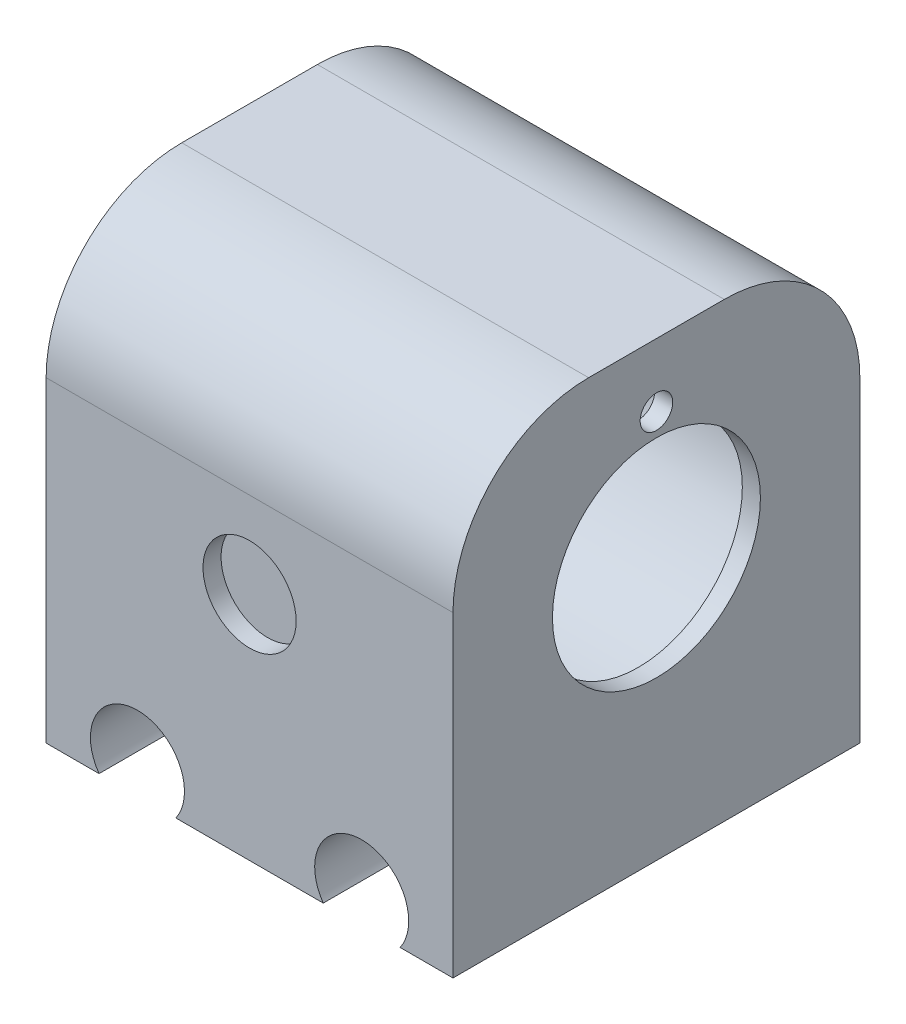
from build123d import *

# Parameters (mm, degrees)
SKETCH1_W           = 45
SKETCH1_H           = 50
BOSS_EXTRUDE1_DEPTH = 45
SKETCH2_R           = 5.2
CUT_EXTRUDE1_DEPTH  = 45
SKETCH9_R           = 5.15
CUT_EXTRUDE6_DEPTH  = 2
SKETCH10_R          = 5.15
CUT_EXTRUDE7_DEPTH  = 2
SKETCH12_R          = 18.375
CUT_EXTRUDE8_DEPTH  = 45
SKETCH13_W          = 45
SKETCH13_H          = 6.66747138
CUT_EXTRUDE9_DEPTH  = 46
SKETCH14_W          = 45
SKETCH14_H          = 6.66747138
BOSS_EXTRUDE2_DEPTH = 45
SKETCH15_R          = 18.375
CUT_EXTRUDE10_DEPTH = 45
FILLET1_R           = 15
SKETCH16_R          = 18.375
BOSS_EXTRUDE3_DEPTH = 2
SKETCH17_R          = 11.5
CUT_EXTRUDE11_DEPTH = 2
SKETCH18_R          = 1.8
CUT_EXTRUDE12_DEPTH = 2


with BuildPart() as part:
    # Sketch1 → Boss-Extrude1 (new body)
    with BuildSketch(Plane.XY):
        with Locations((8.236607143, -2.901785714)):
            Rectangle(SKETCH1_W, SKETCH1_H)
    extrude(amount=BOSS_EXTRUDE1_DEPTH)

    # Sketch2 → Cut-Extrude1 (cut)
    with BuildSketch(Plane.XY.offset(45)):
        with Locations((-4.163392857, -24.901785714)):
            Circle(SKETCH2_R)
        with Locations((20.636607143, -24.901785714)):
            Circle(SKETCH2_R)
    extrude(amount=-CUT_EXTRUDE1_DEPTH, mode=Mode.SUBTRACT)

    # Sketch9 → Cut-Extrude6 (cut)
    with BuildSketch(Plane.XY.offset(45)):
        with Locations((8.236607143, -2.401785714)):
            Circle(SKETCH9_R)
    extrude(amount=-CUT_EXTRUDE6_DEPTH, mode=Mode.SUBTRACT)

    # Sketch10 → Cut-Extrude7 (cut)
    with BuildSketch(Plane(origin=(0, 0, 0), x_dir=(-1, 0, 0), z_dir=(0, 0, -1))):
        with Locations((-8.236607143, -2.401785714)):
            Circle(SKETCH10_R)
    extrude(amount=-CUT_EXTRUDE7_DEPTH, mode=Mode.SUBTRACT)

    # Sketch12 → Cut-Extrude8 (cut)
    with BuildSketch(Plane.ZY.offset(14.263392857)):
        with Locations((22.5, 1.098214286)):
            Circle(SKETCH12_R)
    extrude(amount=-CUT_EXTRUDE8_DEPTH, mode=Mode.SUBTRACT)

    # Sketch13 → Cut-Extrude9 (cut)
    with BuildSketch(Plane.ZY.offset(14.263392857)):
        with Locations((22.5, 18.764478596)):
            Rectangle(SKETCH13_W, SKETCH13_H)
    extrude(amount=-CUT_EXTRUDE9_DEPTH, mode=Mode.SUBTRACT)

    # Sketch14 → Boss-Extrude2 (add)
    with BuildSketch(Plane.ZY.offset(14.263392857)):
        with Locations((22.5, 18.764478596)):
            Rectangle(SKETCH14_W, SKETCH14_H)
    extrude(amount=-BOSS_EXTRUDE2_DEPTH)

    # Sketch15 → Cut-Extrude10 (cut)
    with BuildSketch(Plane.ZY.offset(14.263392857)):
        with Locations((22.5, 1.098214286)):
            Circle(SKETCH15_R)
    extrude(amount=-CUT_EXTRUDE10_DEPTH, mode=Mode.SUBTRACT)

    # Fillet1
    fillet1_edges = [part.edges().sort_by_distance(p)[0] for p in [
        (8.236607143, 22.098214286, 0),
        (8.236607143, 22.098214286, 45),
    ]]
    fillet(fillet1_edges, radius=FILLET1_R)

    # Sketch16 → Boss-Extrude3 (add)
    with BuildSketch(Plane(origin=(30.736607143, 0, 0), x_dir=(0, 0, -1), z_dir=(1, 0, 0))):
        with Locations((-22.5, 1.098214286)):
            Circle(SKETCH16_R)
    extrude(amount=-BOSS_EXTRUDE3_DEPTH)

    # Sketch17 → Cut-Extrude11 (cut)
    with BuildSketch(Plane(origin=(30.736607143, 0, 0), x_dir=(0, 0, -1), z_dir=(1, 0, 0))):
        with Locations((-22.5, 1.098214286)):
            Circle(SKETCH17_R)
    extrude(amount=-CUT_EXTRUDE11_DEPTH, mode=Mode.SUBTRACT)

    # Sketch18 → Cut-Extrude12 (cut)
    with BuildSketch(Plane(origin=(30.736607143, 0, 0), x_dir=(0, 0, -1), z_dir=(1, 0, 0))):
        with Locations((-22.5, 15.098214286)):
            Circle(SKETCH18_R)
    extrude(amount=-CUT_EXTRUDE12_DEPTH, mode=Mode.SUBTRACT)


solid = part.part
